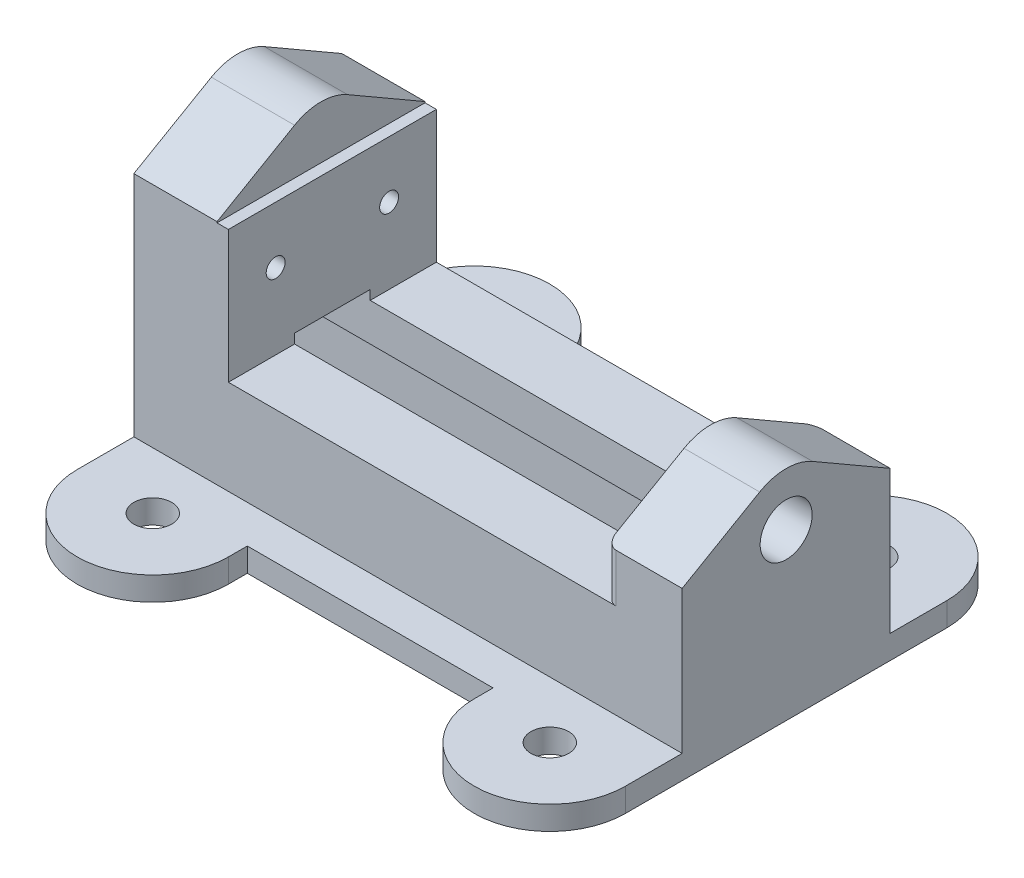
from build123d import *

# Parameters (mm, degrees)
SKETCH1_W                           = 184.15
SKETCH1_H                           = 39.6875
EXTRUDE1_DEPTH                      = 34.925
SKETCH2_W                           = 31.75
SKETCH2_H                           = 44.45
EXTRUDE2_DEPTH                      = 69.85
EXTRUDE3_DEPTH                      = 25.4
CUT_EXTRUDE1_START                  = -15.24
CUT_EXTRUDE1_DEPTH                  = 169.91
EXTRUDE4_DEPTH                      = 7.9375
EXTRUDE5_DEPTH                      = 7.9375
SKETCH17_W                          = 82.55
SKETCH17_H                          = 12.7
EXTRUDE7_DEPTH                      = 7.9375
F_1_2_0_5_DIAMETER_HOLE1_D          = 12.7
EXTRUDE6_DEPTH                      = 27.94
F_1_4_0_25_DIAMETER_HOLE2_D         = 6.35
F_1_4_0_25_DIAMETER_HOLE2_DEPTH     = 15.875
F_1_4_0_25_DIAMETER_HOLE2_TIP       = 1.907732465
F_11_16_0_6875_DIAMETER_HOLE1_D     = 17.4625
F_11_16_0_6875_DIAMETER_HOLE1_DEPTH = 25.4
FILLET15_R                          = 3.175


with BuildPart() as part:
    # Sketch1 → Extrude1 (new body, symmetric)
    with BuildSketch(Plane.XY):
        with Locations((92.075, 19.84375)):
            Rectangle(SKETCH1_W, SKETCH1_H)
    extrude(amount=EXTRUDE1_DEPTH, both=True)

    # Sketch2 → Extrude2 (add)
    with BuildSketch(Plane.XY.offset(34.925)):
        with Locations((15.875, 61.9125)):
            Rectangle(SKETCH2_W, SKETCH2_H)
    extrude(amount=-EXTRUDE2_DEPTH)

    # Sketch3 → Extrude3 (add)
    with BuildSketch(Plane(origin=(184.15, 0, 0), x_dir=(0, 0, -1), z_dir=(1, 0, 0))):
        with BuildLine():
            Line((-34.925, 39.6875), (34.925, 39.6875))
            Line((34.925, 39.6875), (34.925, 55.929117421))
            Line((34.925, 55.929117421), (8.89, 70.960431679))
            ThreePointArc((8.89, 70.960431679), (0, 73.3425), (-8.89, 70.960431679))
            Line((-8.89, 70.960431679), (-34.925, 55.929117421))
            Line((-34.925, 55.929117421), (-34.925, 39.6875))
        make_face()
    extrude(amount=-EXTRUDE3_DEPTH)

    # Sketch4 → Cut-Extrude1 (cut, through all)
    with BuildSketch(Plane(origin=(184.15, 0, 0), x_dir=(0, 0, -1), z_dir=(1, 0, 0)).offset(CUT_EXTRUDE1_START)):
        Polygon((-15.875, 0), (15.875, 0), (15.875, 26.9875), (12.7, 26.9875), (12.7, 42.8625), (-12.7, 42.8625), (-12.7, 26.9875), (-15.875, 26.9875), align=None)
    extrude(amount=-CUT_EXTRUDE1_DEPTH, mode=Mode.SUBTRACT)

    # Sketch5 → Extrude4 (add)
    with BuildSketch(Plane.XZ):
        with BuildLine():
            Line((50.8, 53.975), (50.8, 34.925))
            Line((50.8, 34.925), (0, 34.925))
            Line((0, 34.925), (0, 53.975))
            ThreePointArc((0, 53.975), (25.4, 79.375), (50.8, 53.975))
        make_face()
    extrude4 = extrude(amount=-EXTRUDE4_DEPTH)

    # Sketch6 → Extrude5 (add)
    with BuildSketch(Plane.XZ):
        with BuildLine():
            Line((184.15, 34.925), (133.35, 34.925))
            Line((133.35, 34.925), (133.35, 53.975))
            ThreePointArc((133.35, 53.975), (158.75, 79.375), (184.15, 53.975))
            Line((184.15, 53.975), (184.15, 34.925))
        make_face()
    extrude5 = extrude(amount=-EXTRUDE5_DEPTH)

    # Sketch17 → Extrude7 (add)
    with BuildSketch(Plane.XZ):
        with Locations((92.075, 41.275)):
            Rectangle(SKETCH17_W, SKETCH17_H)
    extrude7 = extrude(amount=-EXTRUDE7_DEPTH)

    # 1/2 (0.5) Diameter Hole1 (through all)
    with Locations(Plane(origin=(0, 7.9375, 0), x_dir=(-1, 0, 0), z_dir=(0, 1, 0))):
        with Locations((-25.4, 53.975), (-158.75, 53.975)):
            f_1_2_0_5_diameter_hole1 = Hole(F_1_2_0_5_DIAMETER_HOLE1_D / 2)

    # Mirror1: Extrude4, Extrude5, Extrude7, 1/2 (0.5) Diameter Hole1 across plane
    add(extrude4.mirror(Plane.XY))
    add(extrude5.mirror(Plane.XY))
    add(extrude7.mirror(Plane.XY))
    add(f_1_2_0_5_diameter_hole1.mirror(Plane.XY), mode=Mode.SUBTRACT)

    # Sketch16 → Extrude6 (add)
    with BuildSketch(Plane(origin=(0, 0, 0), x_dir=(0, 0, -1), z_dir=(1, 0, 0))):
        with BuildLine():
            Line((-34.925, 84.1375), (34.925, 84.1375))
            Line((34.925, 84.1375), (34.925, 84.504117421))
            Line((34.925, 84.504117421), (8.89, 99.535431679))
            ThreePointArc((8.89, 99.535431679), (0, 101.9175), (-8.89, 99.535431679))
            Line((-8.89, 99.535431679), (-34.925, 84.504117421))
            Line((-34.925, 84.504117421), (-34.925, 84.1375))
        make_face()
    extrude(amount=EXTRUDE6_DEPTH)

    # 1/4 (0.25) Diameter Hole2
    with Locations(Plane(origin=(31.75, 0, 0), x_dir=(0, 0, -1), z_dir=(1, 0, 0))):
        with Locations((-19.05, 65.0875), (19.05, 65.0875)):
            Hole(F_1_4_0_25_DIAMETER_HOLE2_D / 2, depth=F_1_4_0_25_DIAMETER_HOLE2_DEPTH)
            with Locations((0, 0, -(F_1_4_0_25_DIAMETER_HOLE2_DEPTH + F_1_4_0_25_DIAMETER_HOLE2_TIP / 2))):  # 118° drill point
                Cone(0, F_1_4_0_25_DIAMETER_HOLE2_D / 2, F_1_4_0_25_DIAMETER_HOLE2_TIP, mode=Mode.SUBTRACT)

    # 11/16 (0.6875) Diameter Hole1
    with Locations(Plane(origin=(184.15, 0, 0), x_dir=(0, 0, -1), z_dir=(1, 0, 0))):
        with Locations((0, 55.5625)):
            Hole(F_11_16_0_6875_DIAMETER_HOLE1_D / 2, depth=F_11_16_0_6875_DIAMETER_HOLE1_DEPTH)

    # Fillet15
    fillet15_edges = [part.edges().sort_by_distance(p)[0] for p in [
        (158.75, 47.80830871, 34.925),
        (158.75, 47.80830871, -34.925),
    ]]
    fillet(fillet15_edges, radius=FILLET15_R)


solid = part.part
